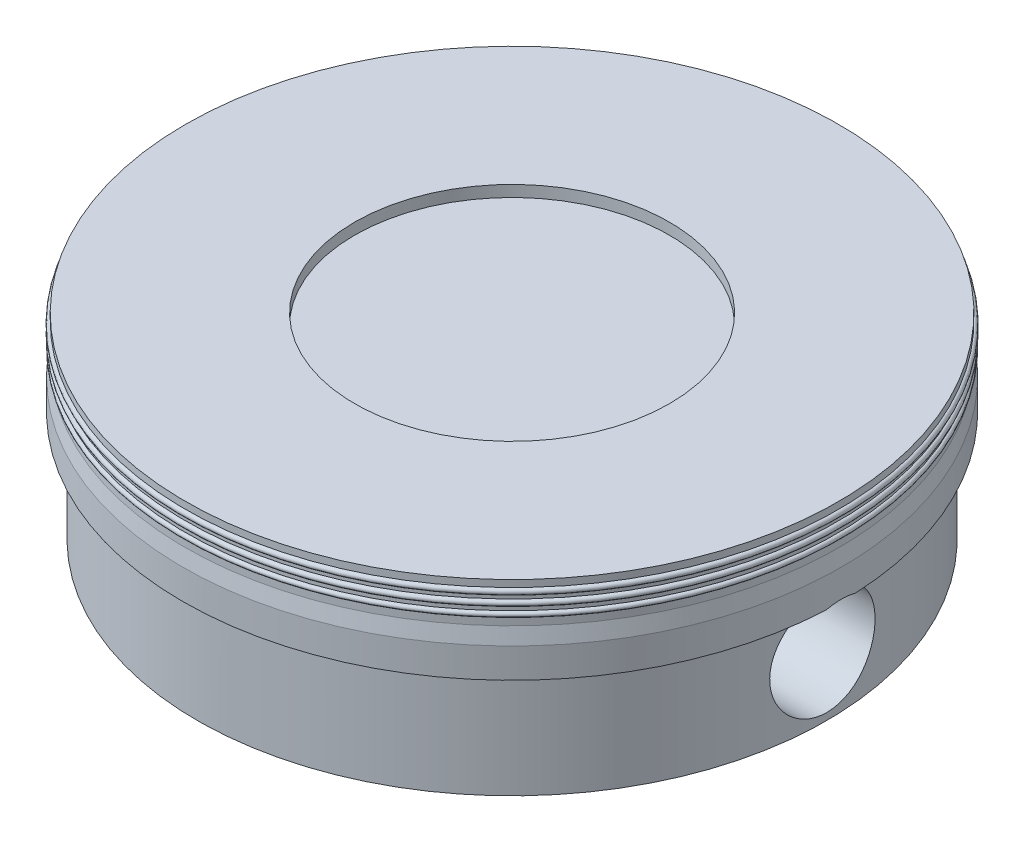
from build123d import *

# Parameters (mm, degrees)
BOSS_EXTRUDE1_REACH     = 31.72
SKETCH4_R               = 8
CUT_EXTRUDE1_DEPTH      = 51.051664689
CUT_EXTRUDE1_DEPTH_BACK = 51.051664789
SCALE1_SCALE            = 0.1


with BuildPart() as part:
    # Sketch2 → Revolve1 (revolve)
    with BuildSketch(Plane.XY):
        with BuildLine():
            Line((47.8, 0), (34.3, 0))
            Line((34.3, 0), (34.3, 19.3))
            Line((34.3, 19.3), (42, 19.3))
            Line((42, 19.3), (42, 23.3))
            Line((42, 23.3), (0, 23.3))
            Line((0, 23.3), (0, 28))
            Line((0, 28), (23.9, 28))
            Line((23.9, 28), (23.9, 29.72))
            Line((23.9, 29.72), (49.6, 29.72))
            Line((49.6, 29.72), (49.6, 28.671664689))
            ThreePointArc((49.6, 28.671664689), (50.051664689, 28.22), (49.6, 27.768335311))
            Line((49.6, 27.768335311), (49.6, 27.163130292))
            ThreePointArc((49.6, 27.163130292), (50.043130292, 26.72), (49.6, 26.276869708))
            Line((49.6, 26.276869708), (49.6, 25.62))
            ThreePointArc((49.6, 25.62), (50, 25.22), (49.6, 24.82))
            Line((49.6, 24.82), (49.6, 23.626841788))
            Line((49.6, 23.626841788), (50, 21.266091104))
            Line((50, 21.266091104), (50, 16.75))
            Line((50, 16.75), (47.8, 16.75))
            Line((47.8, 16.75), (47.8, 0))
        make_face()
    revolve(axis=Axis((0, 30, 0), (0, -1, 0)))

    # Sketch3 → Boss-Extrude1 (add, up to next)
    with BuildSketch(Plane.XZ, mode=Mode.PRIVATE) as boss_extrude1_sk1:
        with BuildLine():
            Line((-17.5, 29.499830508), (-17.5, -29.499830508))
            ThreePointArc((-17.5, -29.499830508), (-34.3, 0), (-17.5, 29.499830508))
        make_face()
    boss_extrude1_tool1 = extrude(boss_extrude1_sk1.sketch, amount=-BOSS_EXTRUDE1_REACH, mode=Mode.PRIVATE) - part.part
    add(boss_extrude1_tool1.solids().sort_by_distance((-24.384651, 0, 0))[0])
    # Sketch3 → Boss-Extrude1 (add, up to next)
    with BuildSketch(Plane.XZ, mode=Mode.PRIVATE) as boss_extrude1_sk2:
        with BuildLine():
            Line((17.5, 29.499830508), (17.5, -29.499830508))
            ThreePointArc((17.5, -29.499830508), (34.3, 0), (17.5, 29.499830508))
        make_face()
    boss_extrude1_tool2 = extrude(boss_extrude1_sk2.sketch, amount=-BOSS_EXTRUDE1_REACH, mode=Mode.PRIVATE) - part.part
    add(boss_extrude1_tool2.solids().sort_by_distance((24.384651, 0, 0))[0])

    # Sketch4 → Cut-Extrude1 (cut, two sides)
    with BuildSketch(Plane(origin=(0, 0, 0), x_dir=(0, 0, -1), z_dir=(1, 0, 0))) as cut_extrude1_sk:
        with Locations((0, 9.065)):
            Circle(SKETCH4_R)
    extrude(amount=CUT_EXTRUDE1_DEPTH, mode=Mode.SUBTRACT)
    extrude(cut_extrude1_sk.sketch, amount=-CUT_EXTRUDE1_DEPTH_BACK, mode=Mode.SUBTRACT)


with BuildPart() as part_1:
    # Scale1: scaled about (9.67e-07, 16.354771304, 3.0579e-05)
    add(part.part.scale(SCALE1_SCALE).moved(Location((8.7e-07, 14.719294174, 2.7521e-05))))


solid = part_1.part
